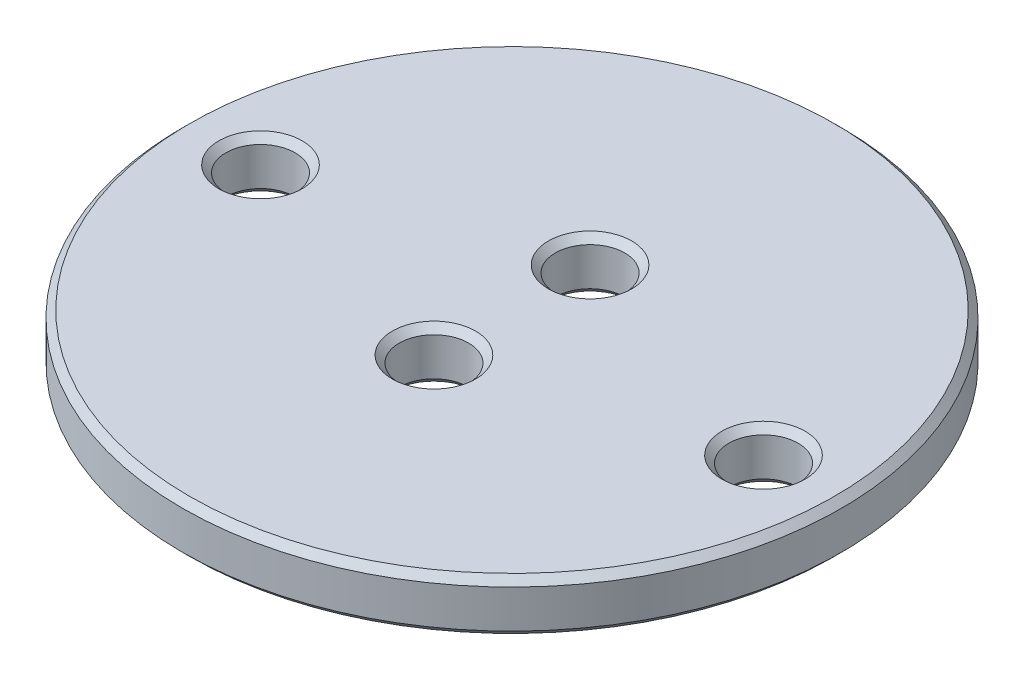
from build123d import *

# Parameters (mm, degrees)
SKETCH1_R           = 19
SKETCH1_R_2         = 2
BOSS_EXTRUDE1_DEPTH = 3
CHAMFER1_SIZE       = 0.4


with BuildPart() as part:
    # Sketch1 → Boss-Extrude1 (new body)
    with BuildSketch(Plane(origin=(0, 0, 0), x_dir=(1, 0, 0), z_dir=(0, 1, 0))):
        Circle(SKETCH1_R)
        with Locations((-14.5, 0)):
            Circle(SKETCH1_R_2, mode=Mode.SUBTRACT)
        with Locations((14.5, 0)):
            Circle(SKETCH1_R_2, mode=Mode.SUBTRACT)
        with Locations((0, 4.5)):
            Circle(SKETCH1_R_2, mode=Mode.SUBTRACT)
        with Locations((0, -4.5)):
            Circle(SKETCH1_R_2, mode=Mode.SUBTRACT)
    extrude(amount=BOSS_EXTRUDE1_DEPTH)

    # Chamfer1
    chamfer1_edges = [part.edges().sort_by_distance(p)[0] for p in [
        (-2, 0, -4.5),
        (-2, 3, -4.5),
        (-2, 0, 4.5),
        (-2, 3, 4.5),
        (-19, 0, 0),
        (-19, 3, 0),
        (-16.5, 0, 0),
        (-16.5, 3, 0),
        (12.5, 0, 0),
        (12.5, 3, 0),
    ]]
    chamfer(chamfer1_edges, length=CHAMFER1_SIZE)


solid = part.part
